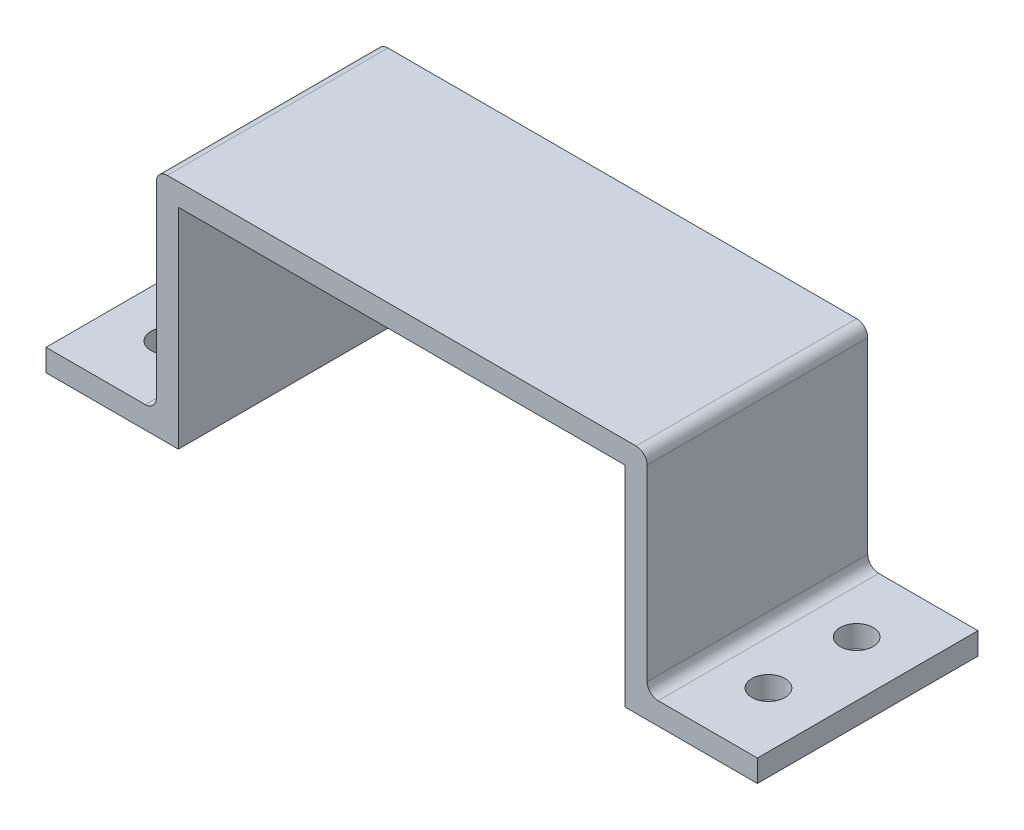
from build123d import *

# Parameters (mm, degrees)
BOSS_EXTRUDE1_DEPTH = 20
SKETCH3_R           = 1.5
CUT_EXTRUDE1_DEPTH  = 3
FILLET1_R           = 1


with BuildPart() as part:
    # Sketch2 → Boss-Extrude1 (new body)
    with BuildSketch(Plane.XY):
        Polygon((-20.25, 19), (20.25, 19), (20.25, 0), (32.25, 0), (32.25, 2), (22.25, 2), (22.25, 21), (-22.25, 21), (-22.25, 2), (-32.25, 2), (-32.25, 0), (-20.25, 0), align=None)
    extrude(amount=BOSS_EXTRUDE1_DEPTH)

    # Sketch3 → Cut-Extrude1 (cut, through all)
    with BuildSketch(Plane(origin=(0, 2, 0), x_dir=(1, 0, 0), z_dir=(0, 1, 0))):
        with Locations((27.25, -6)):
            Circle(SKETCH3_R)
        with Locations((27.25, -14)):
            Circle(SKETCH3_R)
        with Locations((-27.25, -14)):
            Circle(SKETCH3_R)
        with Locations((-27.25, -6)):
            Circle(SKETCH3_R)
    extrude(amount=-CUT_EXTRUDE1_DEPTH, mode=Mode.SUBTRACT)

    # Fillet1
    fillet1_edges = [part.edges().sort_by_distance(p)[0] for p in [
        (-22.25, 2, 10),
        (-22.25, 21, 10),
        (22.25, 21, 10),
        (22.25, 2, 10),
    ]]
    fillet(fillet1_edges, radius=FILLET1_R)


solid = part.part
